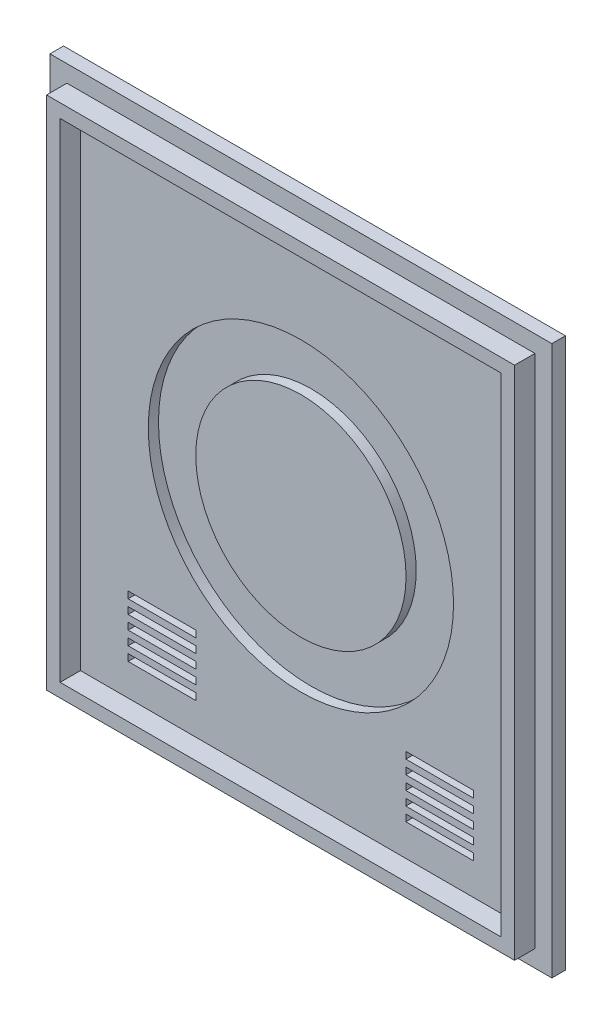
from build123d import *

# Parameters (mm, degrees)
SKIZZE1_W                       = 74
SKIZZE1_H                       = 81
AUFSATZ_LINEAR_AUSTRAGEN1_DEPTH = 2
SKIZZE2_W                       = 69
SKIZZE2_H                       = 76
SKIZZE2_W_2                     = 65
SKIZZE2_H_2                     = 72
AUFSATZ_LINEAR_AUSTRAGEN2_DEPTH = 3
SKIZZE3_R                       = 22.5
SKIZZE3_R_2                     = 15.5
SCHNITT_LINEAR_AUSTRAGEN3_DEPTH = 1.5
SKIZZE4_W                       = 10
SKIZZE4_H                       = 1
SCHNITT_LINEAR_AUSTRAGEN4_DEPTH = 3
SKIZZE5_W                       = 10
SKIZZE5_H                       = 1
SCHNITT_LINEAR_AUSTRAGEN5_DEPTH = 3


with BuildPart() as part:
    # Skizze1 → Aufsatz-Linear austragen1 (new body)
    with BuildSketch(Plane.XY):
        with Locations((-4.260212221, -20.15)):
            Rectangle(SKIZZE1_W, SKIZZE1_H)
    extrude(amount=AUFSATZ_LINEAR_AUSTRAGEN1_DEPTH)

    # Skizze2 → Aufsatz-Linear austragen2 (add)
    with BuildSketch(Plane.XY.offset(2)):
        with Locations((-4.260212221, -20.15)):
            Rectangle(SKIZZE2_W, SKIZZE2_H)
        with Locations((-4.260212221, -20.15)):
            Rectangle(SKIZZE2_W_2, SKIZZE2_H_2, mode=Mode.SUBTRACT)
    extrude(amount=AUFSATZ_LINEAR_AUSTRAGEN2_DEPTH)

    # Skizze3 → Schnitt-Linear austragen3 (cut)
    with BuildSketch(Plane.XY.offset(2)):
        with Locations((-4.260212221, -20.15)):
            Circle(SKIZZE3_R)
        with Locations((-4.260212221, -20.15)):
            Circle(SKIZZE3_R_2, mode=Mode.SUBTRACT)
    extrude(amount=-SCHNITT_LINEAR_AUSTRAGEN3_DEPTH, mode=Mode.SUBTRACT)

    # Skizze4 → Schnitt-Linear austragen4 (cut, through all)
    with BuildSketch(Plane.XY.offset(2)):
        with Locations((-24.731661751, -48.968325553)):
            Rectangle(SKIZZE4_W, SKIZZE4_H)
        with Locations((-24.731661751, -50.968325553)):
            Rectangle(SKIZZE4_W, SKIZZE4_H)
        with Locations((-24.731661751, -46.968325553)):
            Rectangle(SKIZZE4_W, SKIZZE4_H)
        with Locations((-24.731661751, -44.968325553)):
            Rectangle(SKIZZE4_W, SKIZZE4_H)
        with Locations((-24.731661751, -42.968325553)):
            Rectangle(SKIZZE4_W, SKIZZE4_H)
    extrude(amount=-SCHNITT_LINEAR_AUSTRAGEN4_DEPTH, mode=Mode.SUBTRACT)

    # Skizze5 → Schnitt-Linear austragen5 (cut, through all)
    with BuildSketch(Plane.XY.offset(2)):
        with Locations((16.209787779, -50.968325553)):
            Rectangle(SKIZZE5_W, SKIZZE5_H)
        with Locations((16.209787779, -48.968325553)):
            Rectangle(SKIZZE5_W, SKIZZE5_H)
        with Locations((16.209787779, -46.968325553)):
            Rectangle(SKIZZE5_W, SKIZZE5_H)
        with Locations((16.209787779, -44.968325553)):
            Rectangle(SKIZZE5_W, SKIZZE5_H)
        with Locations((16.209787779, -42.968325553)):
            Rectangle(SKIZZE5_W, SKIZZE5_H)
    extrude(amount=-SCHNITT_LINEAR_AUSTRAGEN5_DEPTH, mode=Mode.SUBTRACT)


solid = part.part
